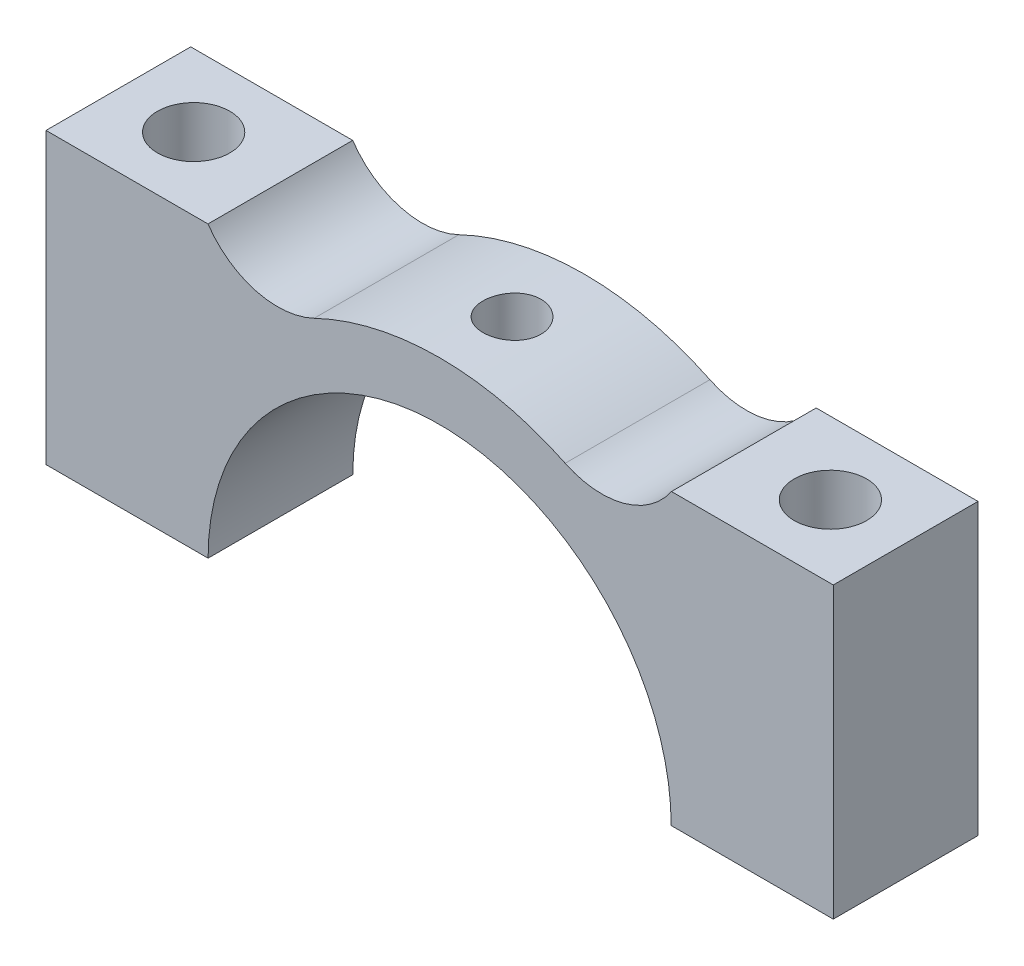
from build123d import *

# Parameters (mm, degrees)
BOSS_EXTRUDE1_DEPTH     = 5
CUT_EXTRUDE1_DEPTH      = 300
CUT_EXTRUDE1_DEPTH_BACK = 18.605680901
SKETCH3_R               = 1.25
SKETCH4_R               = 1
CUT_EXTRUDE2_DEPTH      = 18.605680901


with BuildPart() as part:
    # Sketch2 → Boss-Extrude1 (new body)
    with BuildSketch(Plane.XY):
        with BuildLine():
            ThreePointArc((-8, 0), (0, 8), (8, 0))
            Line((8, 0), (13.6, 0))
            Line((13.6, 0), (13.6, 10))
            Line((13.6, 10), (8.008871246, 10))
            ThreePointArc((8.008871246, 10), (6.357463889, 8.822466805), (4.337930538, 9.01012534))
            ThreePointArc((4.337930538, 9.01012534), (0.001186479, 9.99999993), (-4.335792351, 9.011154459))
            ThreePointArc((-4.335792351, 9.011154459), (-6.353531515, 8.82385013), (-8.003690819, 10))
            Line((-8.003690819, 10), (-13.6, 10))
            Line((-13.6, 10), (-13.6, 0))
            Line((-13.6, 0), (-8, 0))
        make_face()
    extrude(amount=BOSS_EXTRUDE1_DEPTH)

    # Sketch3 → Cut-Extrude1 (cut, two sides: drawn at the far end of the back side and taken through both)
    with BuildSketch(Plane(origin=(0, 10, 0), x_dir=(1, 0, 0), z_dir=(0, 1, 0)).offset(-CUT_EXTRUDE1_DEPTH_BACK)):
        with Locations((-10.998930891, -2.5)):
            Circle(SKETCH3_R)
        with Locations((11.001069109, -2.5)):
            Circle(SKETCH3_R)
    extrude(amount=CUT_EXTRUDE1_DEPTH + CUT_EXTRUDE1_DEPTH_BACK, mode=Mode.SUBTRACT)

    # Sketch4 → Cut-Extrude2 (cut, through all)
    with BuildSketch(Plane(origin=(0, 10, 0), x_dir=(1, 0, 0), z_dir=(0, 1, 0))):
        with Locations((0, -2.5)):
            Circle(SKETCH4_R)
    extrude(amount=-CUT_EXTRUDE2_DEPTH, mode=Mode.SUBTRACT)


solid = part.part
